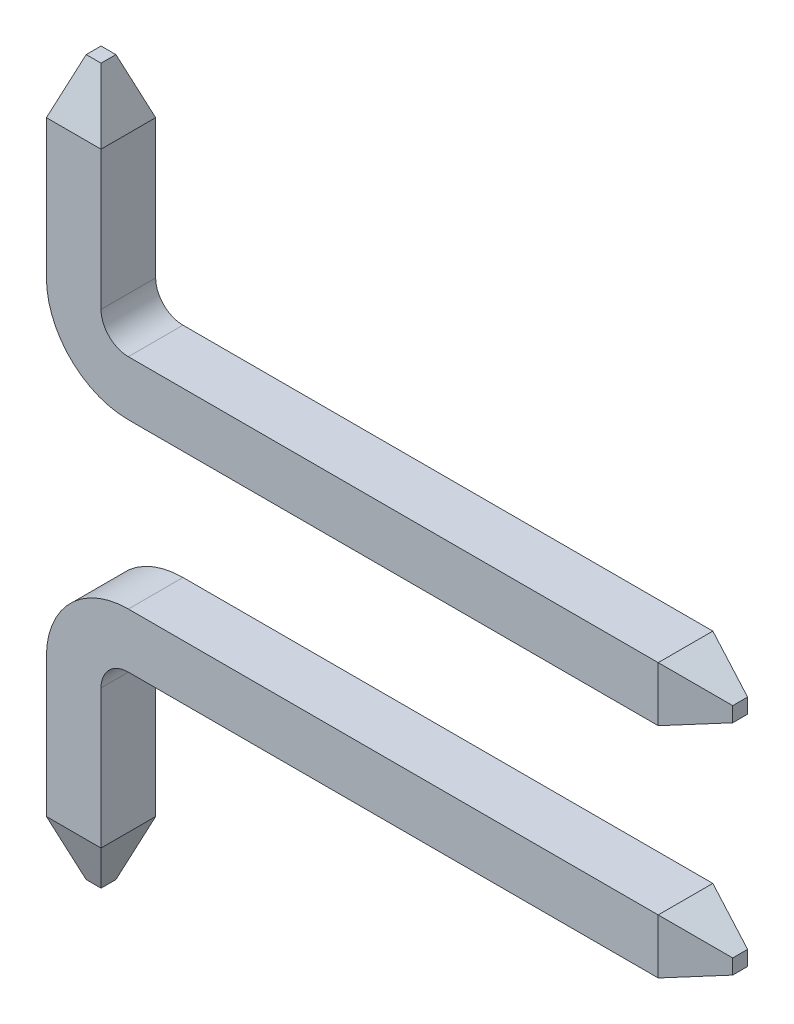
from build123d import *

# Parameters (mm, degrees)
SKETCH1_W           = 0.5
SKETCH1_H           = 0.5
SKETCH6_W           = 0.5
SKETCH6_H           = 0.5
BOSS_EXTRUDE1_DEPTH = 0.5
BOSS_EXTRUDE1_TAPER = 20
SKETCH7_W           = 0.5
SKETCH7_H           = 0.5
BOSS_EXTRUDE2_DEPTH = 0.5
BOSS_EXTRUDE2_TAPER = 20


with BuildPart() as part:
    # Sweep4: sweep along a path in Sketch2
    with BuildLine(Plane.XY) as sweep4_path:
        Line((0.25, 0), (0.25, 1.27))
        ThreePointArc((0.25, 1.27), (0.396446609, 1.623553391), (0.75, 1.77))
        Line((0.75, 1.77), (5.6, 1.77))
    # Sketch1 → Sweep4 (sweep)
    with BuildSketch(Plane(origin=(0, 0, 0), x_dir=(1, 0, 0), z_dir=(0, 1, 0))):
        with Locations((0.25, 0.25)):
            Rectangle(SKETCH1_W, SKETCH1_H)
    sweep(path=sweep4_path.line)

    # Sketch6 → Boss-Extrude1 (add)
    with BuildSketch(Plane(origin=(5.6, 0, 0), x_dir=(0, 0, -1), z_dir=(1, 0, 0))):
        with Locations((0.25, 1.77)):
            Rectangle(SKETCH6_W, SKETCH6_H)
    extrude(amount=BOSS_EXTRUDE1_DEPTH, taper=BOSS_EXTRUDE1_TAPER)

    # Sketch7 → Boss-Extrude2 (add)
    with BuildSketch(Plane.XZ):
        with Locations((0.25, -0.25)):
            Rectangle(SKETCH7_W, SKETCH7_H)
    extrude(amount=BOSS_EXTRUDE2_DEPTH, taper=BOSS_EXTRUDE2_TAPER)


with BuildPart() as body_2:
    # Mirror3: mirrored copy
    add(part.part.mirror(Plane.ZX.offset(2.77)))


solid = Compound([part.part, body_2.part])
